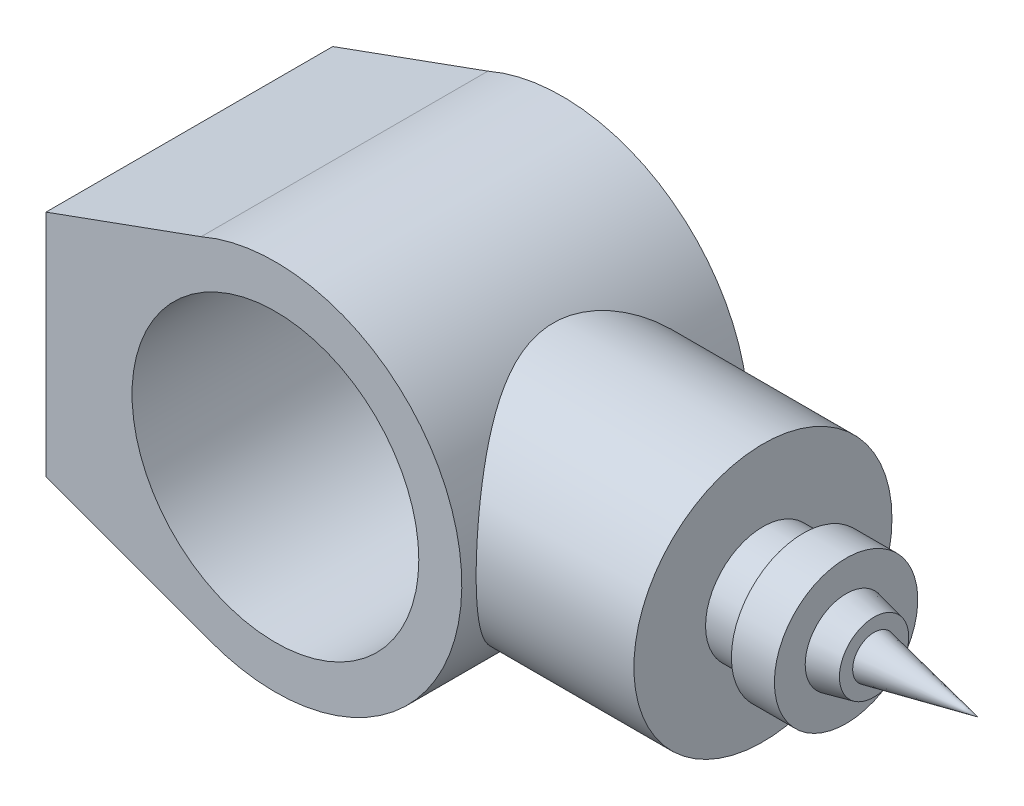
from build123d import *

# Parameters (mm, degrees)
SKETCH1_R           = 50
BOSS_EXTRUDE1_DEPTH = 50
BOSS_EXTRUDE2_REACH = 202
SKETCH2_R           = 45


with BuildPart() as part:
    # Sketch1 → Boss-Extrude1 (new body, symmetric)
    with BuildSketch(Plane.XY):
        with BuildLine():
            Line((-80, -40), (-80, 40))
            Line((-80, 40), (-25.912164589, 59.611741514))
            ThreePointArc((-25.912164589, 59.611741514), (64.980188395, 1.604716841), (-22.938091494, -60.818121959))
            Line((-22.938091494, -60.818121959), (-80, -40))
        make_face()
        Circle(SKETCH1_R, mode=Mode.SUBTRACT)
    extrude(amount=BOSS_EXTRUDE1_DEPTH, both=True)

    # Sketch2 → Boss-Extrude2 (add, up to next)
    with BuildSketch(Plane(origin=(120, 0, 0), x_dir=(0, 0, -1), z_dir=(1, 0, 0)), mode=Mode.PRIVATE) as boss_extrude2_sk1:
        Circle(SKETCH2_R)
    boss_extrude2_tool1 = extrude(boss_extrude2_sk1.sketch, amount=-BOSS_EXTRUDE2_REACH, mode=Mode.PRIVATE) - part.part
    add(boss_extrude2_tool1.solids().sort_by_distance((120, 0, 0))[0])

    # Sketch4 → Revolve2 (revolve)
    with BuildSketch(Plane(origin=(0, 0, 0), x_dir=(1, 0, 0), z_dir=(0, 1, 0))):
        Polygon((120, 0), (195, 0), (158.761034274, -7.465745985), (158.761034274, -12.083492049), (149, -14.256556682), (149, -25), (134, -25), (134, -20), (120, -20), align=None)
    revolve(axis=Axis((0, 0, 0), (1, 0, 0)))


solid = part.part
